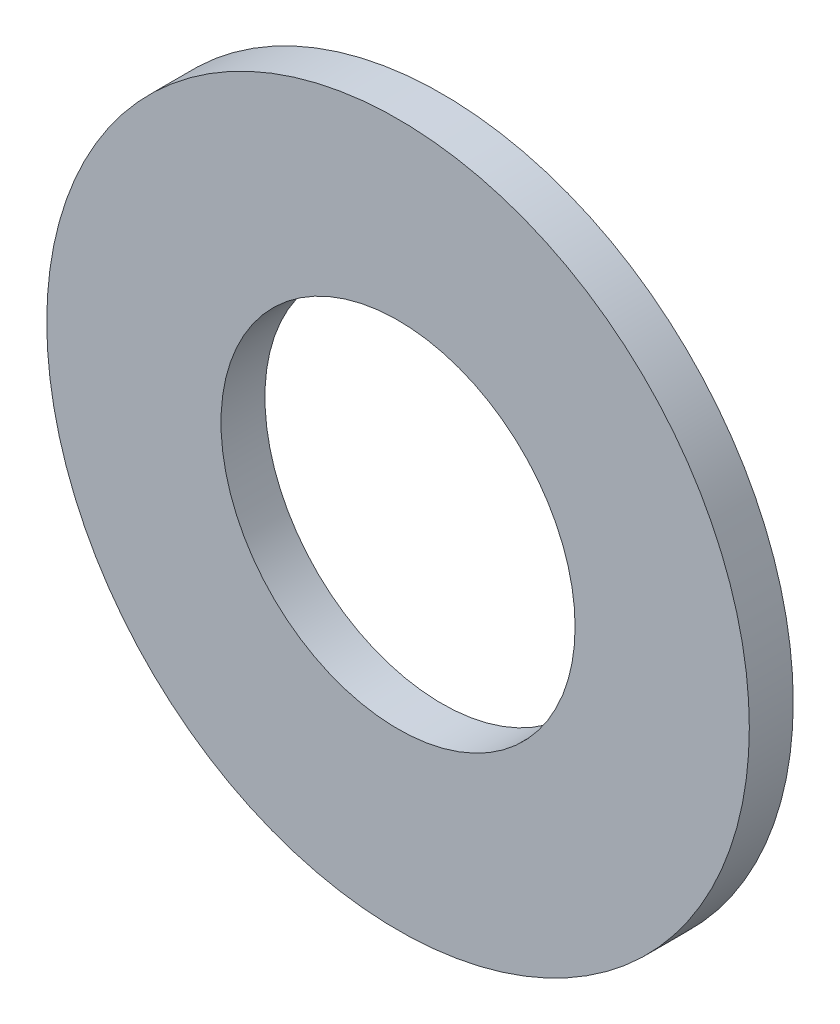
from build123d import *

# Parameters (mm, degrees)
SKETCH1_R      = 12.7
SKETCH1_R_2    = 6.4008
EXTRUDE1_DEPTH = 0.79375


with BuildPart() as part:
    # Sketch1 → Extrude1 (new body, symmetric)
    with BuildSketch(Plane.XY):
        Circle(SKETCH1_R)
        Circle(SKETCH1_R_2, mode=Mode.SUBTRACT)
    extrude(amount=EXTRUDE1_DEPTH, both=True)


solid = part.part
